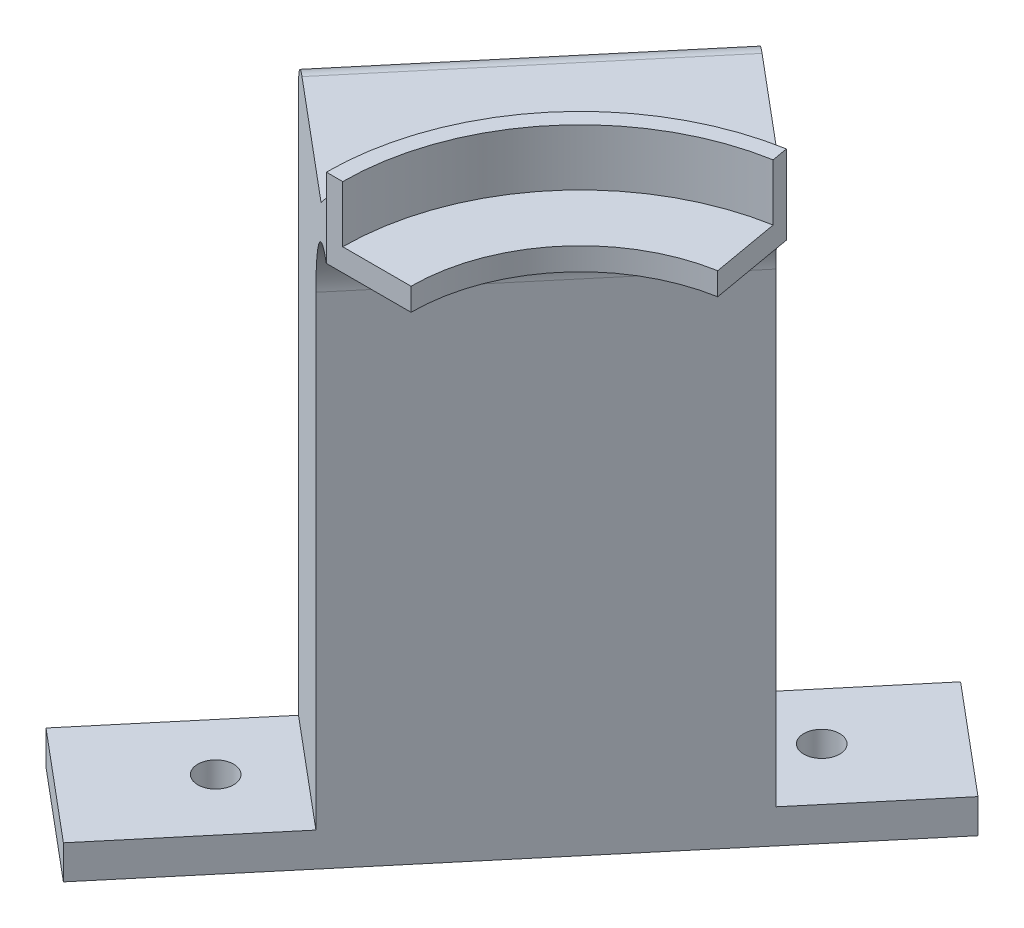
from build123d import *

# Parameters (mm, degrees)
BOSS_EXTRUDE1_DEPTH = 4
BOSS_EXTRUDE2_DEPTH = 14
BOSS_EXTRUDE3_DEPTH = 4
BOSS_EXTRUDE4_DEPTH = 103.5
FILLET1_R           = 15
FILLET2_R           = 5
CHAMFER1_SIZE       = 6
SKETCH6_W           = 25
SKETCH6_H           = 6
BOSS_EXTRUDE5_DEPTH = 25.4
SKETCH7_W           = 25
SKETCH7_H           = 6
BOSS_EXTRUDE6_DEPTH = 31.75
SKETCH8_R           = 2.5527
CUT_EXTRUDE1_DEPTH  = 25.4
SKETCH9_R           = 3.175
CUT_EXTRUDE2_DEPTH  = 25.4


with BuildPart() as part:
    # Sketch1 → Boss-Extrude1 (new body)
    with BuildSketch(Plane(origin=(0, 0, 0), x_dir=(1, 0, 0), z_dir=(0, 1, 0))):
        with BuildLine():
            Line((-42.1, 0), (-30, 0))
            ThreePointArc((-30, 0), (-22.981333, 19.283628), (-5.209445, 29.544233))
            Line((-5.209445, 29.544233), (-7.310588, 41.460406))
            ThreePointArc((-7.310588, 41.460406), (-32.250471, 27.061358), (-42.1, 0))
        make_face()
        with BuildLine():
            Line((-45, 0), (-42.1, 0))
            ThreePointArc((-42.1, 0), (-32.250471, 27.061358), (-7.310588, 41.460406))
            Line((-7.310588, 41.460406), (-7.814168, 44.316349))
            ThreePointArc((-7.814168, 44.316349), (-34.472, 28.925442), (-45, 0))
        make_face()
    extrude(amount=BOSS_EXTRUDE1_DEPTH)

    # Sketch1_3 → Boss-Extrude2 (add)
    with BuildSketch(Plane(origin=(0, 0, 0), x_dir=(1, 0, 0), z_dir=(0, 1, 0))):
        with BuildLine():
            Line((-45, 0), (-42.1, 0))
            ThreePointArc((-42.1, 0), (-32.250471, 27.061358), (-7.310588, 41.460406))
            Line((-7.310588, 41.460406), (-7.814168, 44.316349))
            ThreePointArc((-7.814168, 44.316349), (-34.472, 28.925442), (-45, 0))
        make_face()
    extrude(amount=BOSS_EXTRUDE2_DEPTH)

    # Sketch3 → Boss-Extrude3 (add)
    with BuildSketch(Plane.XZ):
        Polygon((-7.814168, -44.316349), (-45, 0), (-75.641778, -25.711504), (-38.455946, -70.027853), align=None)
    extrude(amount=-BOSS_EXTRUDE3_DEPTH)

    # Sketch4 → Boss-Extrude4 (add)
    with BuildSketch(Plane.XZ):
        Polygon((-38.455946, -70.027853), (-19.304835, -53.958163), (-56.490667, -9.641814), (-75.641778, -25.711504), align=None)
    extrude(amount=BOSS_EXTRUDE4_DEPTH)

    # Fillet1
    fillet1_edges = [part.edges().sort_by_distance(p)[0] for p in [
        (-37.897751, 0, -31.799989),
    ]]
    fillet(fillet1_edges, radius=FILLET1_R)

    # Fillet2
    fillet2_edges = [part.edges().sort_by_distance(p)[0] for p in [
        (-57.048862, 4, -47.869679),
    ]]
    fillet(fillet2_edges, radius=FILLET2_R)

    # Chamfer1
    chamfer1_edges = [part.edges().sort_by_distance(p)[0] for p in [
        (-34.472, 4, -28.925442),
    ]]
    chamfer(chamfer1_edges, length=CHAMFER1_SIZE)

    # Sketch6 → Boss-Extrude5 (add)
    with BuildSketch(Plane(origin=(18.592916, 0, -22.158174), x_dir=(-0.7660444431189766, 0, -0.6427876096865413), z_dir=(0.6427876096865411, 0, -0.7660444431189765))):
        with Locations((61.972, -100.5)):
            Rectangle(SKETCH6_W, SKETCH6_H)
    extrude(amount=BOSS_EXTRUDE5_DEPTH)

    # Sketch7 → Boss-Extrude6 (add)
    with BuildSketch(Plane(origin=(-18.592916, 0, 22.158174), x_dir=(0.7660444431189769, 0, 0.6427876096865406), z_dir=(-0.6427876096865406, 0, 0.7660444431189769))):
        with Locations((-61.972, -100.5)):
            Rectangle(SKETCH7_W, SKETCH7_H)
    extrude(amount=BOSS_EXTRUDE6_DEPTH)

    # Sketch8 → Cut-Extrude1 (cut)
    with BuildSketch(Plane(origin=(0, -97.5, 0), x_dir=(1, 0, 0), z_dir=(0, 1, 0))):
        with Locations(Location((-73.889481, 9.291988, 0), (0, 0, 270))):
            Circle(SKETCH8_R)
        with Locations(Location((-24.909065, 67.664575, 0), (0, 0, 270))):
            Circle(SKETCH8_R)
    extrude(amount=-CUT_EXTRUDE1_DEPTH, mode=Mode.SUBTRACT)

    # Sketch9 → Cut-Extrude2 (cut)
    with BuildSketch(Plane.XZ.offset(103.5)):
        with Locations(Location((-73.889481, -9.291988, 0), (0, 0, 270))):
            Circle(SKETCH9_R)
        with Locations(Location((-24.909065, -67.664575, 0), (0, 0, 270))):
            Circle(SKETCH9_R)
    extrude(amount=-CUT_EXTRUDE2_DEPTH, mode=Mode.SUBTRACT)


solid = part.part
